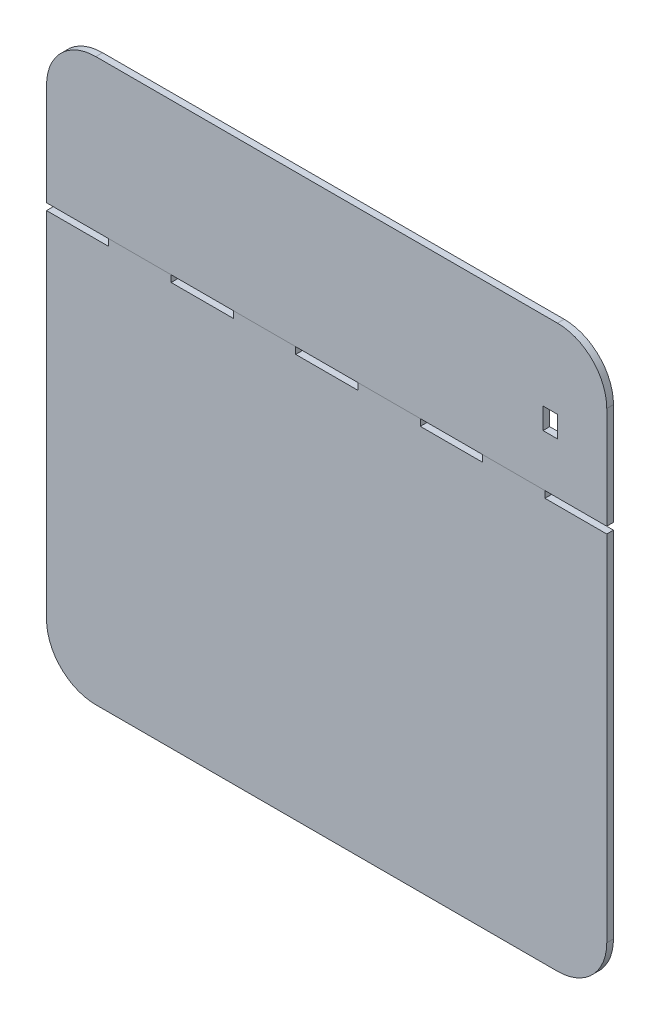
from build123d import *

# Parameters (mm, degrees)
SKETCH1_W              = 500
SKETCH1_H              = 501
BOSS_EXTRUDE1_DEPTH    = 6
FILLET1_R              = 44
SKETCH2_W              = 55.5
SKETCH2_H              = 6
CUT_EXTRUDE1_DEPTH     = 10
LPATTERN1_COUNT        = 5
LPATTERN1_PITCH        = 111.2
SKETCH4_W              = 12.9
SKETCH4_H              = 19
CUT_EXTRUDE3_DEPTH     = 10
SPLIT1_SURFACE_1_BACK  = 708.84
SPLIT1_SURFACE_1_DEPTH = 1417.68
SPLIT1_SURFACE_2_BACK  = 708.84
SPLIT1_SURFACE_2_DEPTH = 1417.68


with BuildPart() as part:
    # Sketch1 → Boss-Extrude1 (new body)
    with BuildSketch(Plane.XY):
        with Locations((250, 250.5)):
            Rectangle(SKETCH1_W, SKETCH1_H)
    extrude(amount=BOSS_EXTRUDE1_DEPTH)

    # Fillet1
    fillet1_edges = [part.edges().sort_by_distance(p)[0] for p in [
        (0, 501, 3),
        (500, 501, 3),
        (500, 0, 3),
        (0, 0, 3),
    ]]
    fillet(fillet1_edges, radius=FILLET1_R)

    # Sketch2 → Cut-Extrude1 (cut)
    with BuildSketch(Plane(origin=(0, 0, 0), x_dir=(-1, 0, 0), z_dir=(0, 0, -1))):
        with Locations((-27.75, 363)):
            Rectangle(SKETCH2_W, SKETCH2_H)
    cut_extrude1 = extrude(amount=-CUT_EXTRUDE1_DEPTH, mode=Mode.SUBTRACT)

    # LPattern1: Cut-Extrude1 ×5
    with Locations(*[(i * LPATTERN1_PITCH, 0, 0) for i in range(1, LPATTERN1_COUNT)]):
        add(cut_extrude1, mode=Mode.SUBTRACT)

    # Sketch4 → Cut-Extrude3 (cut)
    with BuildSketch(Plane(origin=(0, 0, 0), x_dir=(-1, 0, 0), z_dir=(0, 0, -1))):
        with Locations((-449.55, 421)):
            Rectangle(SKETCH4_W, SKETCH4_H)
    extrude(amount=-CUT_EXTRUDE3_DEPTH, mode=Mode.SUBTRACT)


with BuildPart() as body_2:
    # Split1: the piece behind the surface
    add(part.part)
    # Split1 surface: a surface, the sketch's curves swept straight by 1417.68 mm
    with BuildLine(Plane.XY.offset(6).offset(-SPLIT1_SURFACE_1_BACK), mode=Mode.PRIVATE) as split1_surface_1_path:
        Line((0, 366), (500, 366))
    split1_surface_1 = Shell.extrude(split1_surface_1_path.wire(), (0 * SPLIT1_SURFACE_1_DEPTH, 0 * SPLIT1_SURFACE_1_DEPTH, 1 * SPLIT1_SURFACE_1_DEPTH))
    split(bisect_by=split1_surface_1, keep=Keep.BOTTOM)


with BuildPart() as part_1:
    add(part.part)

    # Split1: split by a surface, the side it looks to stays
    # Split1 surface: a surface, the sketch's curves swept straight by 1417.68 mm
    with BuildLine(Plane.XY.offset(6).offset(-SPLIT1_SURFACE_2_BACK), mode=Mode.PRIVATE) as split1_surface_2_path:
        Line((0, 366), (500, 366))
    split1_surface_2 = Shell.extrude(split1_surface_2_path.wire(), (0 * SPLIT1_SURFACE_2_DEPTH, 0 * SPLIT1_SURFACE_2_DEPTH, 1 * SPLIT1_SURFACE_2_DEPTH))
    split(bisect_by=split1_surface_2, keep=Keep.TOP)


solid = Compound([body_2.part, part_1.part])
